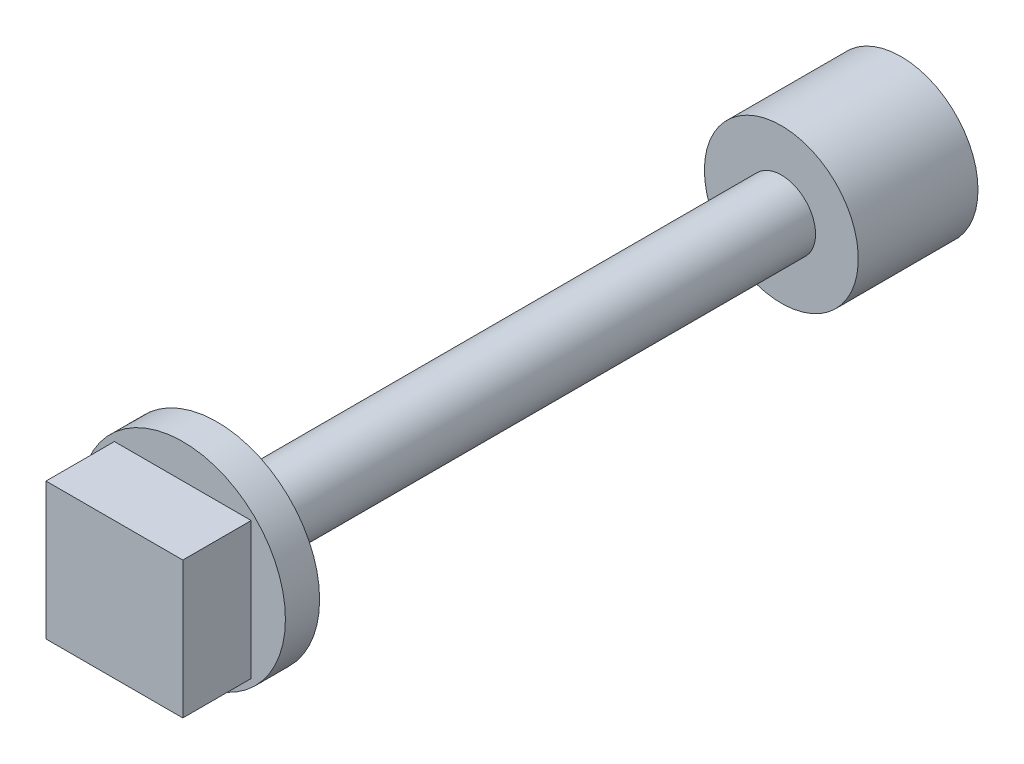
from build123d import *

# Parameters (mm, degrees)
SKETCH_1_R          = 2.25
EXTRUDE_2_DEPTH     = 20
SKETCH_7_W          = 2.4
SKETCH_7_H          = 2.4
CUT_EXTRUDE_3_DEPTH = 2.5
SKETCH_9_R          = 3
EXTRUDE_4_DEPTH     = 1
SKETCH_10_W         = 4
SKETCH_10_H         = 4
EXTRUDE_5_DEPTH     = 2
CUT_EXTRUDE_START   = -20
SKETCH_12_OUTSIDE_W = 12.904
SKETCH_12_OUTSIDE_H = 12.904
SKETCH_12_OUTSIDE_R = 1
CUT_EXTRUDE_4_DEPTH = 16.5


with BuildPart() as part:
    # 草图1 → 凸台-拉伸2 (new body)
    with BuildSketch(Plane.XY):
        Circle(SKETCH_1_R)
    extrude(amount=EXTRUDE_2_DEPTH)

    # 草图7 → 切除-拉伸3 (cut)
    with BuildSketch(Plane.XY):
        Rectangle(SKETCH_7_W, SKETCH_7_H)
    extrude(amount=CUT_EXTRUDE_3_DEPTH, mode=Mode.SUBTRACT)

    # 草图9 → 凸台-拉伸4 (add)
    with BuildSketch(Plane.XY.offset(20)):
        Circle(SKETCH_9_R)
    extrude(amount=EXTRUDE_4_DEPTH)

    # 草图10 → 凸台-拉伸5 (add)
    with BuildSketch(Plane.XY.offset(21)):
        Rectangle(SKETCH_10_W, SKETCH_10_H)
    extrude(amount=EXTRUDE_5_DEPTH)

    # 草图12 outside → 切除-拉伸4 (cut)
    with BuildSketch(Plane(origin=(0, 0, 0), x_dir=(-1, 0, 0), z_dir=(0, 0, -1)).offset(CUT_EXTRUDE_START)):
        Rectangle(SKETCH_12_OUTSIDE_W, SKETCH_12_OUTSIDE_H)
        Circle(SKETCH_12_OUTSIDE_R, mode=Mode.SUBTRACT)
    extrude(amount=CUT_EXTRUDE_4_DEPTH, mode=Mode.SUBTRACT)


solid = part.part
